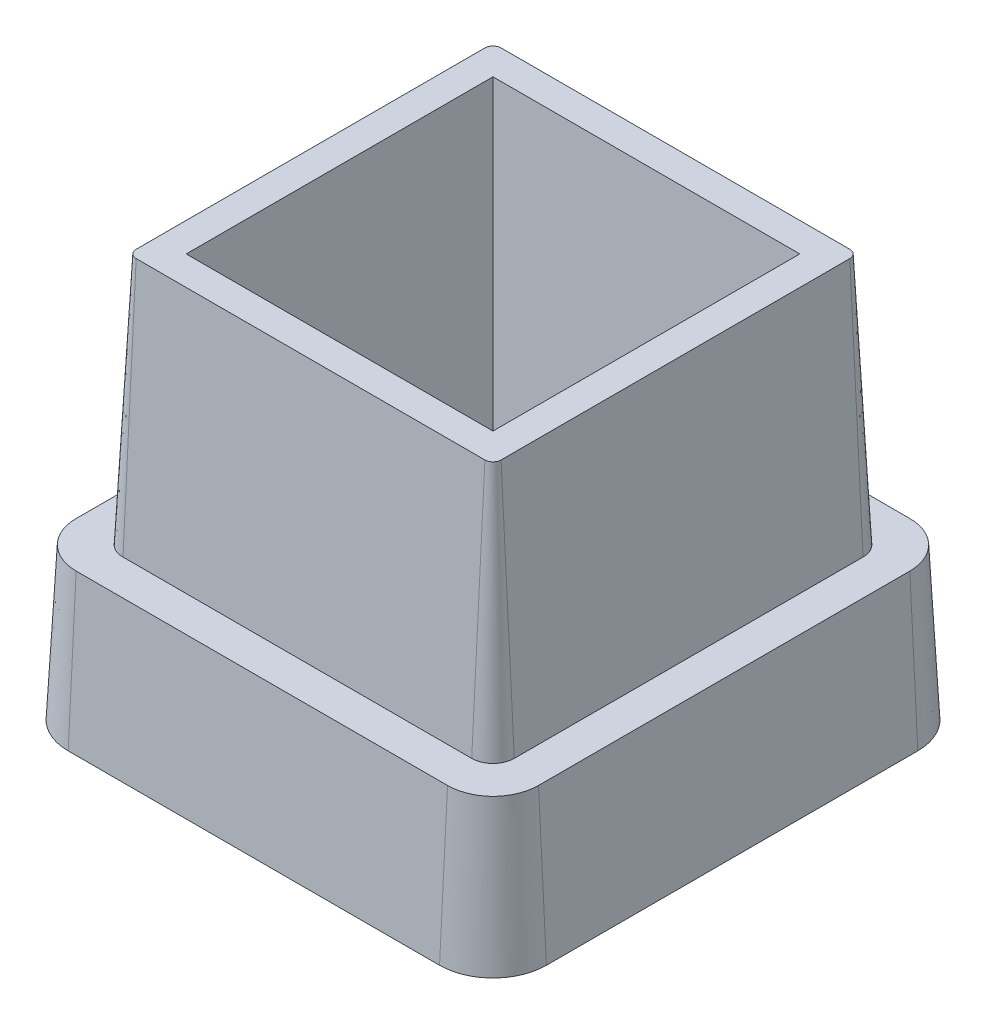
from build123d import *

# Parameters (mm, degrees)
SKETCH1_W           = 27
SKETCH1_H           = 27
BOSS_EXTRUDE1_DEPTH = 25
SKETCH2_W           = 27
SKETCH2_H           = 27
SKETCH2_W_2         = 22.6
SKETCH2_H_2         = 22.6
CUT_EXTRUDE1_DEPTH  = 15.6
SKETCH3_W           = 19
SKETCH3_H           = 19
CUT_EXTRUDE2_DEPTH  = 22.8
FILLET1_R           = 0.5
FILLET2_R           = 2
DRAFT12_ANGLE       = 3


with BuildPart() as part:
    # Sketch1 → Boss-Extrude1 (new body)
    with BuildSketch(Plane(origin=(0, 0, 0), x_dir=(1, 0, 0), z_dir=(0, 1, 0))):
        Rectangle(SKETCH1_W, SKETCH1_H)
    extrude(amount=BOSS_EXTRUDE1_DEPTH)

    # Sketch2 → Cut-Extrude1 (cut)
    with BuildSketch(Plane(origin=(0, 25, 0), x_dir=(1, 0, 0), z_dir=(0, 1, 0))):
        Rectangle(SKETCH2_W, SKETCH2_H)
        Rectangle(SKETCH2_W_2, SKETCH2_H_2, mode=Mode.SUBTRACT)
    extrude(amount=-CUT_EXTRUDE1_DEPTH, mode=Mode.SUBTRACT)

    # Sketch3 → Cut-Extrude2 (cut)
    with BuildSketch(Plane(origin=(0, 25, 0), x_dir=(1, 0, 0), z_dir=(0, 1, 0))):
        Rectangle(SKETCH3_W, SKETCH3_H)
    extrude(amount=-CUT_EXTRUDE2_DEPTH, mode=Mode.SUBTRACT)

    # Fillet1
    fillet1_edges = [part.edges().sort_by_distance(p)[0] for p in [
        (-11.3, 17.2, 11.3),
        (-11.3, 17.2, -11.3),
        (11.3, 17.2, -11.3),
        (11.3, 17.2, 11.3),
    ]]
    fillet(fillet1_edges, radius=FILLET1_R)

    # Fillet2
    fillet2_edges = [part.edges().sort_by_distance(p)[0] for p in [
        (-13.5, 4.7, -13.5),
        (13.5, 4.7, -13.5),
        (13.5, 4.7, 13.5),
        (-13.5, 4.7, 13.5),
    ]]
    fillet(fillet2_edges, radius=FILLET2_R)

    # Draft12
    draft12_faces = [part.faces().sort_by_distance(p)[0] for p in [
        (13.5, 4.7, 0),
        (9.5, 13.6, 0),
        (0, 13.6, 9.5),
        (-9.5, 13.6, 0),
        (0, 13.6, -9.5),
        (-11.153553391, 17.2, -11.153553391),
        (-12.914213562, 4.7, -12.914213562),
        (-13.5, 4.7, 0),
        (-11.3, 17.2, 0),
        (-11.153553391, 17.2, 11.153553391),
        (-12.914213562, 4.7, 12.914213562),
        (0, 4.7, 13.5),
        (12.914213562, 4.7, 12.914213562),
        (11.153553391, 17.2, 11.153553391),
        (0, 17.2, 11.3),
        (11.3, 17.2, 0),
        (11.153553391, 17.2, -11.153553391),
        (0, 17.2, -11.3),
        (0, 4.7, -13.5),
        (12.914213562, 4.7, -12.914213562),
    ]]
    draft(draft12_faces, Plane.ZX.offset(25), DRAFT12_ANGLE)


solid = part.part
